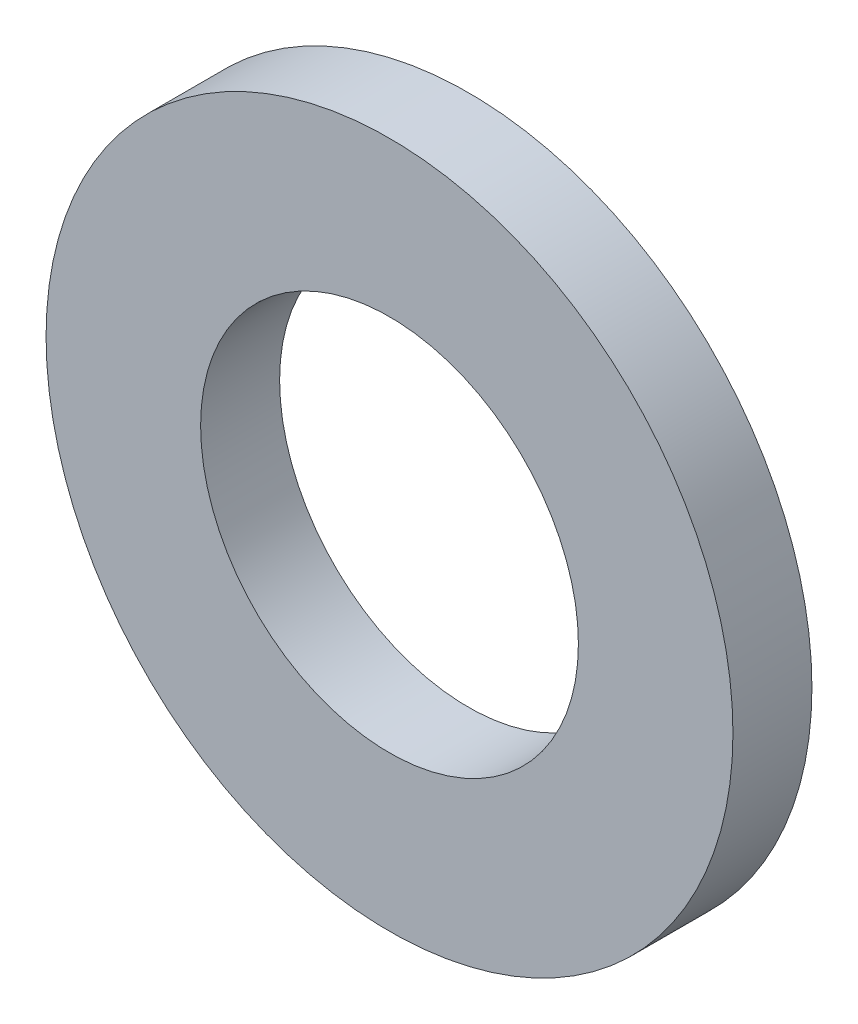
from build123d import *

# Parameters (mm, degrees)
SKICA1_R                = 10
SKICA1_R_2              = 5.5
P_IDAT_VYSUNUT_M1_DEPTH = 2.3


with BuildPart() as part:
    # Skica1 → Přidat vysunutím1 (new body)
    with BuildSketch(Plane.XY):
        Circle(SKICA1_R)
        Circle(SKICA1_R_2, mode=Mode.SUBTRACT)
    extrude(amount=P_IDAT_VYSUNUT_M1_DEPTH)


solid = part.part
